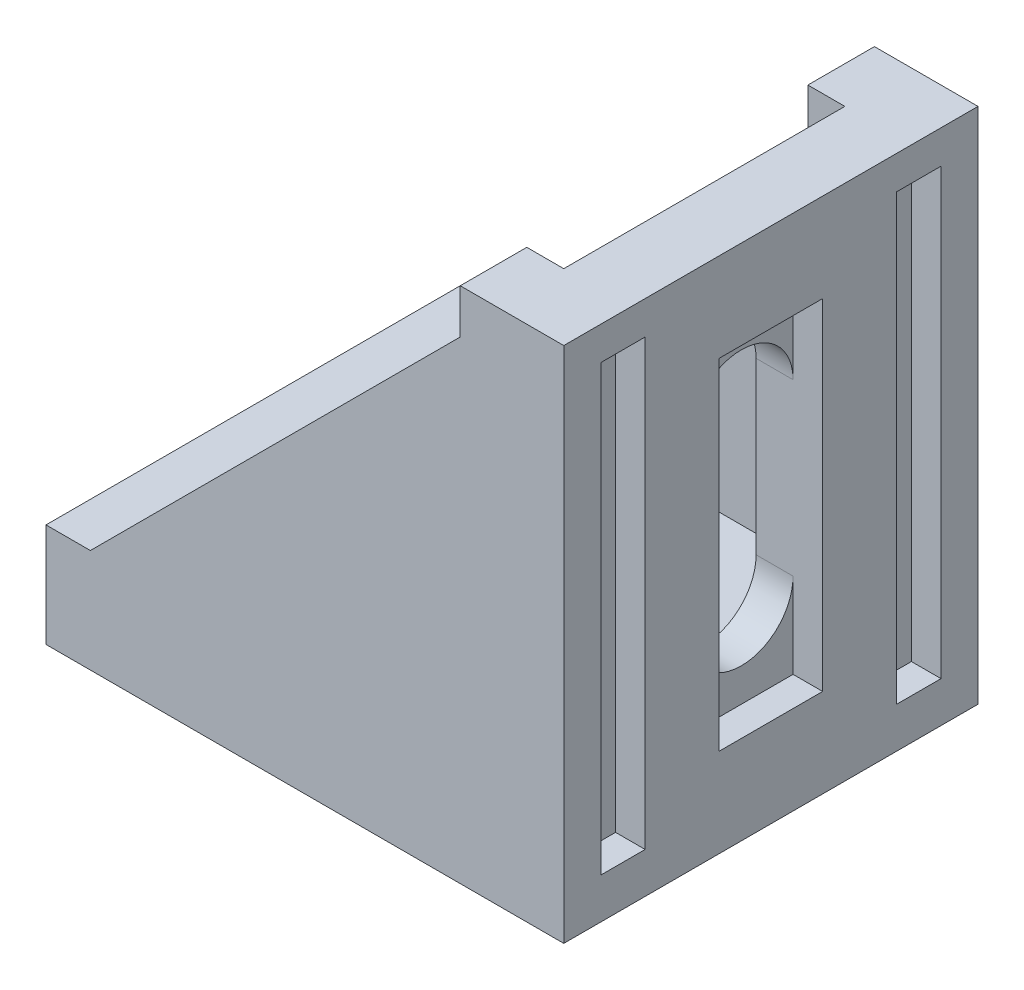
from build123d import *

# Parameters (mm, degrees)
BOSS_EXTRUDE1_DEPTH = 28
SKETCH3_W           = 19
SKETCH3_H           = 28
CUT_EXTRUDE1_DEPTH  = 30.5
SKETCH4_W           = 3
SKETCH4_H           = 30
CUT_EXTRUDE2_DEPTH  = 2
CUT_EXTRUDE3_DEPTH  = 36
SKETCH6_W           = 7
SKETCH6_H           = 23
CUT_EXTRUDE4_DEPTH  = 2
SKETCH11_W          = 29.75
SKETCH11_H          = 3
SKETCH11_W_2        = 23
SKETCH11_H_2        = 7
CUT_EXTRUDE6_DEPTH  = 2
CUT_EXTRUDE7_DEPTH  = 34


with BuildPart() as part:
    # Sketch1 → Boss-Extrude1 (new body)
    with BuildSketch(Plane.XY):
        Polygon((0, 0), (35, 0), (35, 35), (28, 35), (28, 32), (3, 7), (0, 7), align=None)
    extrude(amount=BOSS_EXTRUDE1_DEPTH)

    # Sketch3 → Cut-Extrude1 (cut)
    with BuildSketch(Plane.ZY):
        with Locations((14, 21)):
            Rectangle(SKETCH3_W, SKETCH3_H)
    extrude(amount=-CUT_EXTRUDE1_DEPTH, mode=Mode.SUBTRACT)

    # Sketch4 → Cut-Extrude2 (cut)
    with BuildSketch(Plane(origin=(35, 0, 0), x_dir=(0, 0, -1), z_dir=(1, 0, 0))):
        with Locations((-24, 17.75)):
            Rectangle(SKETCH4_W, SKETCH4_H)
        with Locations((-4, 17.75)):
            Rectangle(SKETCH4_W, SKETCH4_H)
    extrude(amount=-CUT_EXTRUDE2_DEPTH, mode=Mode.SUBTRACT)

    # Sketch5 → Cut-Extrude3 (cut, through all)
    with BuildSketch(Plane(origin=(35, 0, 0), x_dir=(0, 0, -1), z_dir=(1, 0, 0))):
        with BuildLine():
            Line((-10.5, 23.25), (-10.5, 11.75))
            ThreePointArc((-10.5, 11.75), (-14, 8.25), (-17.5, 11.75))
            Line((-17.5, 11.75), (-17.5, 23.25))
            ThreePointArc((-17.5, 23.25), (-14, 26.75), (-10.5, 23.25))
        make_face()
    extrude(amount=-CUT_EXTRUDE3_DEPTH, mode=Mode.SUBTRACT)

    # Sketch6 → Cut-Extrude4 (cut)
    with BuildSketch(Plane(origin=(35, 0, 0), x_dir=(0, 0, -1), z_dir=(1, 0, 0))):
        with Locations((-14, 17.5)):
            Rectangle(SKETCH6_W, SKETCH6_H)
    extrude(amount=-CUT_EXTRUDE4_DEPTH, mode=Mode.SUBTRACT)

    # Sketch11 → Cut-Extrude6 (cut)
    with BuildSketch(Plane.XZ):
        with Locations((17.375, 24)):
            Rectangle(SKETCH11_W, SKETCH11_H)
        with Locations((17.375, 4)):
            Rectangle(SKETCH11_W, SKETCH11_H)
        with Locations((17.5, 14)):
            Rectangle(SKETCH11_W_2, SKETCH11_H_2)
    extrude(amount=-CUT_EXTRUDE6_DEPTH, mode=Mode.SUBTRACT)

    # Sketch12 → Cut-Extrude7 (cut, through all)
    with BuildSketch(Plane.XZ.offset(-2)):
        with BuildLine():
            Line((11.75, 17.5), (23.25, 17.5))
            ThreePointArc((23.25, 17.5), (26.75, 14), (23.25, 10.5))
            Line((23.25, 10.5), (11.75, 10.5))
            ThreePointArc((11.75, 10.5), (8.25, 14), (11.75, 17.5))
        make_face()
    extrude(amount=-CUT_EXTRUDE7_DEPTH, mode=Mode.SUBTRACT)


solid = part.part
